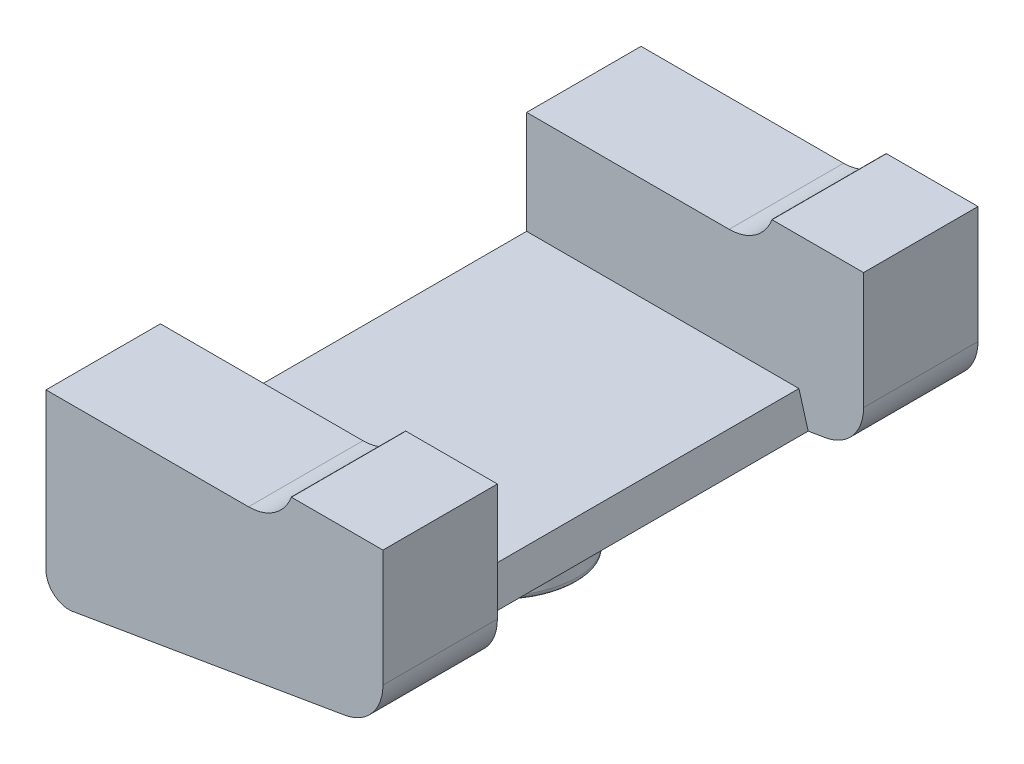
from build123d import *

# Parameters (mm, degrees)
BOSS_EXTRUDE1_DEPTH = 65
CUT_EXTRUDE1_DEPTH  = 40
CUT_EXTRUDE4_DEPTH  = 22.5
SKETCH6_R           = 12.5
SKETCH6_R_2         = 5
BOSS_EXTRUDE2_DEPTH = 12
CHAMFER1_SIZE       = 5
FILLET1_R           = 1
SKETCH7_R           = 1
CUT_EXTRUDE5_DEPTH  = 66


with BuildPart() as part:
    # Sketch1 → Boss-Extrude1 (new body, symmetric)
    with BuildSketch(Plane.XY):
        with BuildLine():
            Line((0, 0), (0, -25.554938316))
            ThreePointArc((0, -25.554938316), (-2.359933303, -32.007021768), (-8.325876175, -35.413807897))
            Line((-8.325876175, -35.413807897), (-67.775097409, -45.508814922))
            ThreePointArc((-67.775097409, -45.508814922), (-71.838201048, -44.399413479), (-73.612159322, -40.579380131))
            Line((-73.612159322, -40.579380131), (-73.612159322, -6.5))
            Line((-73.612159322, -6.5), (-29.367881905, -6.5))
            ThreePointArc((-29.367881905, -6.5), (-23.632117541, -4.691520443), (-19.970955697, 0.079798567))
            Line((-19.970955697, 0.079798567), (-20, 0))
            Line((-20, 0), (0, 0))
        make_face()
    extrude(amount=BOSS_EXTRUDE1_DEPTH, both=True)

    # Sketch2 → Cut-Extrude1 (cut, symmetric)
    with BuildSketch(Plane.XY):
        with BuildLine():
            Line((-20, 0), (-19.970955697, 0.079798567))
            ThreePointArc((-19.970955697, 0.079798567), (-20.672372291, -1.438432196), (-21.617003148, -2.818534521))
            Line((-21.617003148, -2.818534521), (-12.102051753, -36.055036129))
            Line((-12.102051753, -36.055036129), (-8.325876175, -35.413807897))
            ThreePointArc((-8.325876175, -35.413807897), (-2.359933303, -32.007021768), (0, -25.554938316))
            Line((0, -25.554938316), (0, 0))
            Line((0, 0), (-20, 0))
        make_face()
    extrude(amount=CUT_EXTRUDE1_DEPTH, both=True, mode=Mode.SUBTRACT)

    # Sketch5 → Cut-Extrude4 (cut, symmetric)
    with BuildSketch(Plane(origin=(0, -6.5, 0), x_dir=(1, 0, 0), z_dir=(0, 1, 0))):
        Polygon((-73.612159322, 40), (-29.401702386, 40), (0, 40), (0, -40), (-29.367881905, -40), (-73.612159322, -40), align=None)
    extrude(amount=CUT_EXTRUDE4_DEPTH, both=True, mode=Mode.SUBTRACT)

    # Sketch6 → Boss-Extrude2 (add)
    with BuildSketch(Plane(origin=(5.611689276, -33.047085202, 0), x_dir=(0.985886958, 0.167412383, 0), z_dir=(0.167412383, -0.985886958, 0))):
        with Locations((-42.967314491, 0)):
            Circle(SKETCH6_R)
        with Locations((-42.967314491, 0)):
            Circle(SKETCH6_R_2, mode=Mode.SUBTRACT)
    extrude(amount=BOSS_EXTRUDE2_DEPTH)

    # Chamfer1
    chamfer1_edges = [part.edges().sort_by_distance(p)[0] for p in [
        (-49.072812682, -42.333000474, 0),
    ]]
    chamfer(chamfer1_edges, length=CHAMFER1_SIZE)

    # Fillet1
    fillet1_edges = [part.edges().sort_by_distance(p)[0] for p in [
        (-54.002247473, -43.170062387, 0),
        (-47.063864092, -54.163643971, 0),
        (-48.23575077, -47.262435265, 0),
    ]]
    fillet(fillet1_edges, radius=FILLET1_R)

    # Sketch7 → Cut-Extrude5 (cut, through all)
    with BuildSketch(Plane.XY):
        with Locations((-34.907689498, -48.549314554)):
            Circle(SKETCH7_R)
    extrude(amount=-CUT_EXTRUDE5_DEPTH, mode=Mode.SUBTRACT)


solid = part.part
